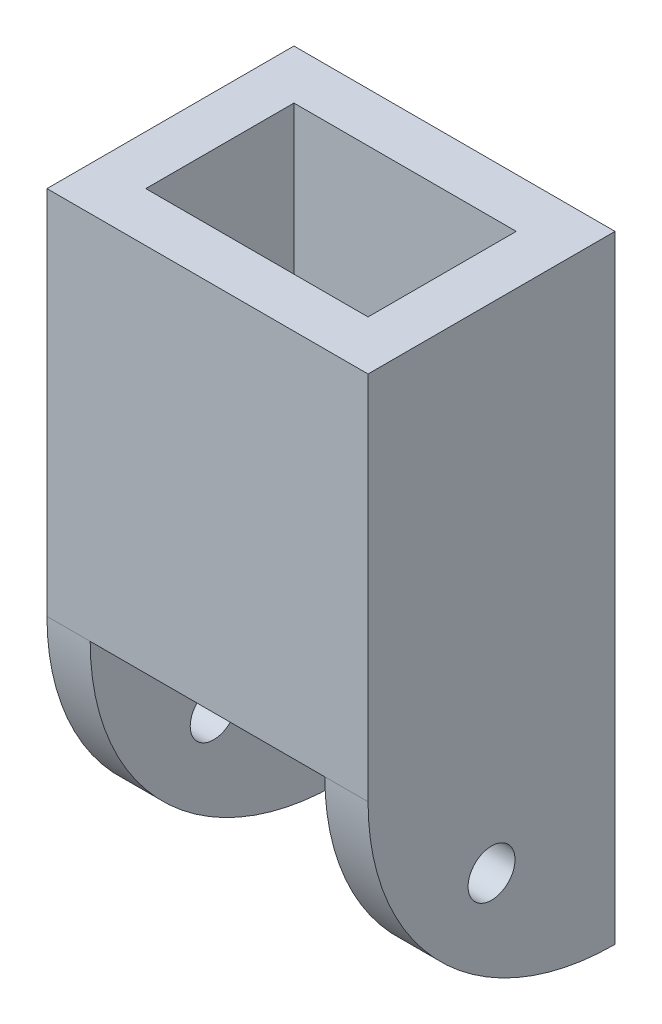
from build123d import *

# Parameters (mm, degrees)
SKETCH1_W               = 13
SKETCH1_H               = 10
SKETCH1_W_2             = 9
SKETCH1_H_2             = 6
BOSS_EXTRUDE1_DEPTH     = 15
BOSS_EXTRUDE2_DEPTH     = 2
SKETCH3_R               = 0.95
CUT_EXTRUDE1_DEPTH      = 14
SKETCH5_W               = 0.25
SKETCH5_H               = 10
CUT_EXTRUDE3_DEPTH      = 6
CUT_EXTRUDE3_DEPTH_BACK = 6
SKETCH6_W               = 8
SKETCH6_H               = 0.8
CUT_EXTRUDE4_DEPTH      = 10


with BuildPart() as part:
    # Sketch1 → Boss-Extrude1 (new body)
    with BuildSketch(Plane(origin=(0, 0, 0), x_dir=(1, 0, 0), z_dir=(0, 1, 0))):
        Rectangle(SKETCH1_W, SKETCH1_H)
        Rectangle(SKETCH1_W_2, SKETCH1_H_2, mode=Mode.SUBTRACT)
    extrude(amount=BOSS_EXTRUDE1_DEPTH)

    # Sketch2 → Boss-Extrude2 (add)
    with BuildSketch(Plane(origin=(6.5, 0, 0), x_dir=(0, 0, -1), z_dir=(1, 0, 0))):
        with BuildLine():
            ThreePointArc((-5, 0), (-2.071067812, -7.071067812), (5, -10))
            Line((5, -10), (5, 0))
            Line((5, 0), (-5, 0))
        make_face()
    boss_extrude2 = extrude(amount=-BOSS_EXTRUDE2_DEPTH)

    # Mirror1: Boss-Extrude2 across plane
    add(boss_extrude2.mirror(Plane(origin=(0, 0, 0), x_dir=(0, 0, 1), z_dir=(1, 0, 0))))

    # Sketch3 → Cut-Extrude1 (cut, through all)
    with BuildSketch(Plane(origin=(6.5, 0, 0), x_dir=(0, 0, -1), z_dir=(1, 0, 0))):
        with Locations((0, -5)):
            Circle(SKETCH3_R)
    extrude(amount=-CUT_EXTRUDE1_DEPTH, mode=Mode.SUBTRACT)

    # Sketch5 → Cut-Extrude3 (cut, two sides)
    with BuildSketch(Plane.XY) as cut_extrude3_sk:
        with Locations((-4.625, -5)):
            Rectangle(SKETCH5_W, SKETCH5_H)
        with Locations((4.625, -5)):
            Rectangle(SKETCH5_W, SKETCH5_H)
    extrude(amount=CUT_EXTRUDE3_DEPTH, mode=Mode.SUBTRACT)
    extrude(cut_extrude3_sk.sketch, amount=-CUT_EXTRUDE3_DEPTH_BACK, mode=Mode.SUBTRACT)

    # Sketch6 → Cut-Extrude4 (cut)
    with BuildSketch(Plane.XZ):
        with Locations((0, 4)):
            Rectangle(SKETCH6_W, SKETCH6_H)
    cut_extrude4 = extrude(amount=-CUT_EXTRUDE4_DEPTH, mode=Mode.SUBTRACT)

    # Mirror2: Cut-Extrude4 across plane
    add(cut_extrude4.mirror(Plane.XY), mode=Mode.SUBTRACT)


solid = part.part
